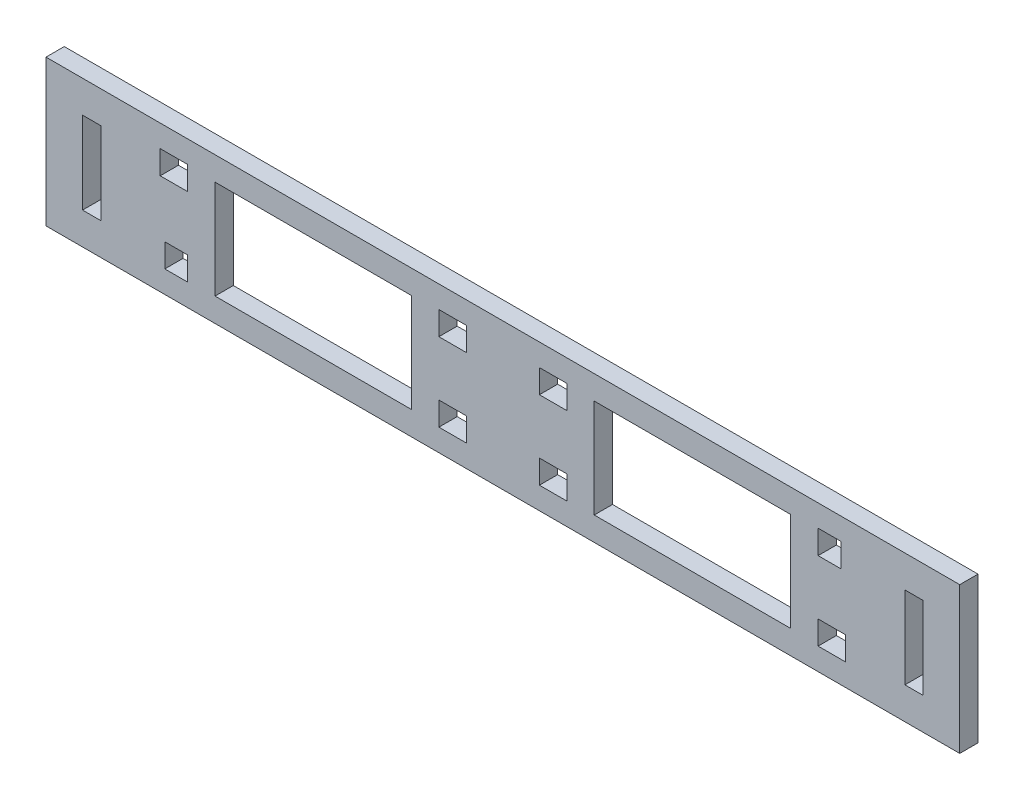
from build123d import *

# Parameters (mm, degrees)
SKETCH2_W           = 200
SKETCH2_H           = 32
BOSS_EXTRUDE1_DEPTH = 4
SKETCH3_W           = 43
SKETCH3_H           = 21.6
SKETCH3_W_2         = 6
SKETCH3_H_2         = 5.15
SKETCH3_W_3         = 5
SKETCH3_W_4         = 4
SKETCH3_H_3         = 18
SKETCH3_H_4         = 5.2
CUT_EXTRUDE1_DEPTH  = 4


with BuildPart() as part:
    # Sketch2 → Boss-Extrude1 (new body)
    with BuildSketch(Plane.XY):
        with Locations((20.66568498, 24.11539075)):
            Rectangle(SKETCH2_W, SKETCH2_H)
    extrude(amount=BOSS_EXTRUDE1_DEPTH)

    # Sketch3 → Cut-Extrude1 (cut)
    with BuildSketch(Plane.XY.offset(4)):
        with Locations((-20.83431502, 24.11539075)):
            Rectangle(SKETCH3_W, SKETCH3_H)
        with Locations((62.16568498, 24.11539075)):
            Rectangle(SKETCH3_W, SKETCH3_H)
        with Locations((31.66568498, 32.69039075)):
            Rectangle(SKETCH3_W_2, SKETCH3_H_2)
        with Locations((-51.33431502, 32.69039075)):
            Rectangle(SKETCH3_W_2, SKETCH3_H_2)
        with Locations((-50.83431502, 15.54039075)):
            Rectangle(SKETCH3_W_3, SKETCH3_H_2)
        with Locations((9.66568498, 32.69039075)):
            Rectangle(SKETCH3_W_2, SKETCH3_H_2)
        with Locations((9.66568498, 15.54039075)):
            Rectangle(SKETCH3_W_2, SKETCH3_H_2)
        with Locations((-69.33431502, 24.11539075)):
            Rectangle(SKETCH3_W_4, SKETCH3_H_3)
        with Locations((31.66568498, 15.54039075)):
            Rectangle(SKETCH3_W_2, SKETCH3_H_2)
        with Locations((92.16568498, 32.71539075)):
            Rectangle(SKETCH3_W_3, SKETCH3_H_4)
        with Locations((92.66568498, 15.54039075)):
            Rectangle(SKETCH3_W_2, SKETCH3_H_2)
        with Locations((110.66568498, 24.11539075)):
            Rectangle(SKETCH3_W_4, SKETCH3_H_3)
    extrude(amount=-CUT_EXTRUDE1_DEPTH, mode=Mode.SUBTRACT)


solid = part.part
